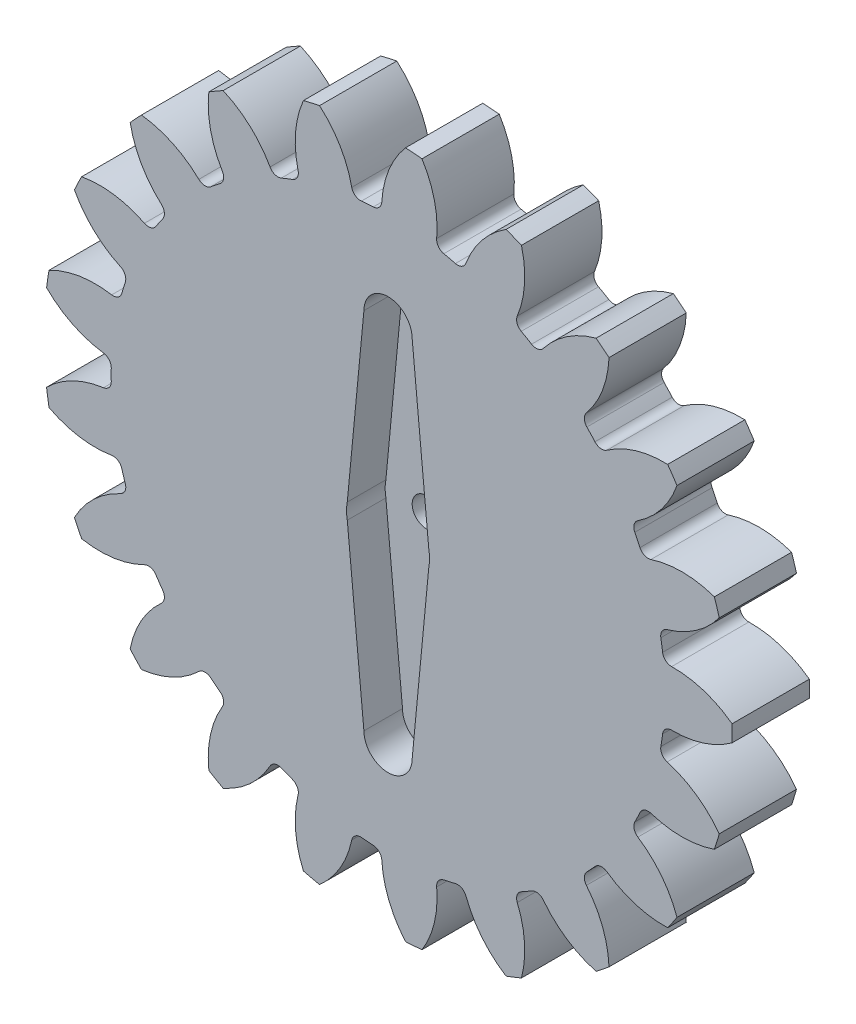
from build123d import *

# Parameters (mm, degrees)
SKETCH1_R                = 35.65
BOSS_EXTRUDE1_DEPTH      = 4
CUT_EXTRUDE1_DEPTH       = 5
FILLET1_R                = 0.93
CIRPATTERN1_COUNT        = 21
FILLET1_OF_CIRPATTERN1_R = 0.93
CUT_EXTRUDE3_DEPTH       = 4
SKETCH6_R                = 1.5
CUT_EXTRUDE4_DEPTH       = 5.0000001
CUT_EXTRUDE4_DEPTH_BACK  = 5.0000001


with BuildPart() as part:
    # Sketch1 → Boss-Extrude1 (new body, symmetric)
    with BuildSketch(Plane.XY):
        Circle(SKETCH1_R)
    extrude(amount=BOSS_EXTRUDE1_DEPTH, both=True)

    # Sketch4 → Cut-Extrude1 (cut, symmetric)
    with BuildSketch(Plane.XY):
        with BuildLine():
            ThreePointArc((-36.242364653, -5.451009479), (-32.872441369, -2.636648824), (-28.63673557, -1.480878422))
            ThreePointArc((-28.63673557, -1.480878422), (-28.675, 0), (-28.63673557, 1.480878422))
            ThreePointArc((-28.63673557, 1.480878422), (-32.872441369, 2.636648824), (-36.242364653, 5.451009479))
            ThreePointArc((-36.242364653, 5.451009479), (-36.65, 0), (-36.242364653, -5.451009479))
        make_face()
    cut_extrude1 = extrude(amount=CUT_EXTRUDE1_DEPTH, both=True, mode=Mode.SUBTRACT)

    # Fillet1
    fillet1_edges = [part.edges().sort_by_distance(p)[0] for p in [
        (-28.63673557, -1.480878422, 0),
        (-28.63673557, 1.480878422, 0),
    ]]
    fillet(fillet1_edges, radius=FILLET1_R)

    # CirPattern1: Cut-Extrude1 ×21 about axis
    cirpattern1_axis = Axis((0, 0, 0), (0, 0, 1))
    for i in range(1, CIRPATTERN1_COUNT):
        add(cut_extrude1.rotate(cirpattern1_axis, i * 360 / CIRPATTERN1_COUNT), mode=Mode.SUBTRACT)

    # Fillet1 of CirPattern1
    fillet1_of_cirpattern1_edges = [part.edges().sort_by_distance(p)[0] for p in [
        (-26.927989179, -9.855913136, 0),
        (-27.800982335, -7.025738839, 0),
        (-22.826572779, -17.355206716, 0),
        (-24.494989816, -14.908088372, 0),
        (-16.696915214, -23.312414018, 0),
        (-19.012509958, -21.46578883, 0),
        (-9.08366346, -27.198211029, 0),
        (-11.840685156, -26.116159749, 0),
        (-0.663288343, -28.667327632, 0),
        (-3.616763515, -28.445995266, 0),
        (7.816022853, -27.589226371, 0),
        (4.928523436, -28.24827927, 0),
        (15.600846118, -24.059701274, 0),
        (13.035889451, -25.540579696, 0),
        (21.999465743, -18.392366134, 0),
        (19.984959482, -20.563487533, 0),
        (26.443336294, -11.09078855, 0),
        (25.15827816, -13.759239261, 0),
        (28.53760037, -2.803745732, 0),
        (28.096173418, -5.732422199, 0),
        (28.096173418, 5.732422199, 0),
        (28.53760037, 2.803745732, 0),
        (25.15827816, 13.759239261, 0),
        (26.443336294, 11.09078855, 0),
        (19.984959482, 20.563487533, 0),
        (21.999465743, 18.392366134, 0),
        (13.035889451, 25.540579696, 0),
        (15.600846118, 24.059701274, 0),
        (4.928523436, 28.24827927, 0),
        (7.816022853, 27.589226371, 0),
        (-3.616763515, 28.445995266, 0),
        (-0.663288343, 28.667327632, 0),
        (-11.840685156, 26.116159749, 0),
        (-9.08366346, 27.198211029, 0),
        (-19.012509958, 21.46578883, 0),
        (-16.696915214, 23.312414018, 0),
        (-24.494989816, 14.908088372, 0),
        (-22.826572779, 17.355206716, 0),
        (-27.800982335, 7.025738839, 0),
        (-26.927989179, 9.855913136, 0),
    ]]
    fillet(fillet1_of_cirpattern1_edges, radius=FILLET1_OF_CIRPATTERN1_R)

    # Sketch5 → Cut-Extrude3 (cut)
    with BuildSketch(Plane.XY.offset(4)):
        with BuildLine():
            Line((-2.5, 18.85), (-4.222289698, 0.813799547))
            ThreePointArc((-4.222289698, 0.813799547), (-4.3, 0), (-4.222289698, -0.813799547))
            Line((-4.222289698, -0.813799547), (-2.5, -18.85))
            ThreePointArc((-2.5, -18.85), (0, -21.35), (2.5, -18.85))
            Line((2.5, -18.85), (4.222289698, -0.813799547))
            ThreePointArc((4.222289698, -0.813799547), (4.3, 0), (4.222289698, 0.813799547))
            Line((4.222289698, 0.813799547), (2.5, 18.85))
            ThreePointArc((2.5, 18.85), (0, 21.35), (-2.5, 18.85))
        make_face()
    extrude(amount=-CUT_EXTRUDE3_DEPTH, mode=Mode.SUBTRACT)

    # Sketch6 → Cut-Extrude4 (cut, two sides)
    with BuildSketch(Plane.XY) as cut_extrude4_sk:
        Circle(SKETCH6_R)
    extrude(amount=CUT_EXTRUDE4_DEPTH, mode=Mode.SUBTRACT)
    extrude(cut_extrude4_sk.sketch, amount=-CUT_EXTRUDE4_DEPTH_BACK, mode=Mode.SUBTRACT)


solid = part.part
